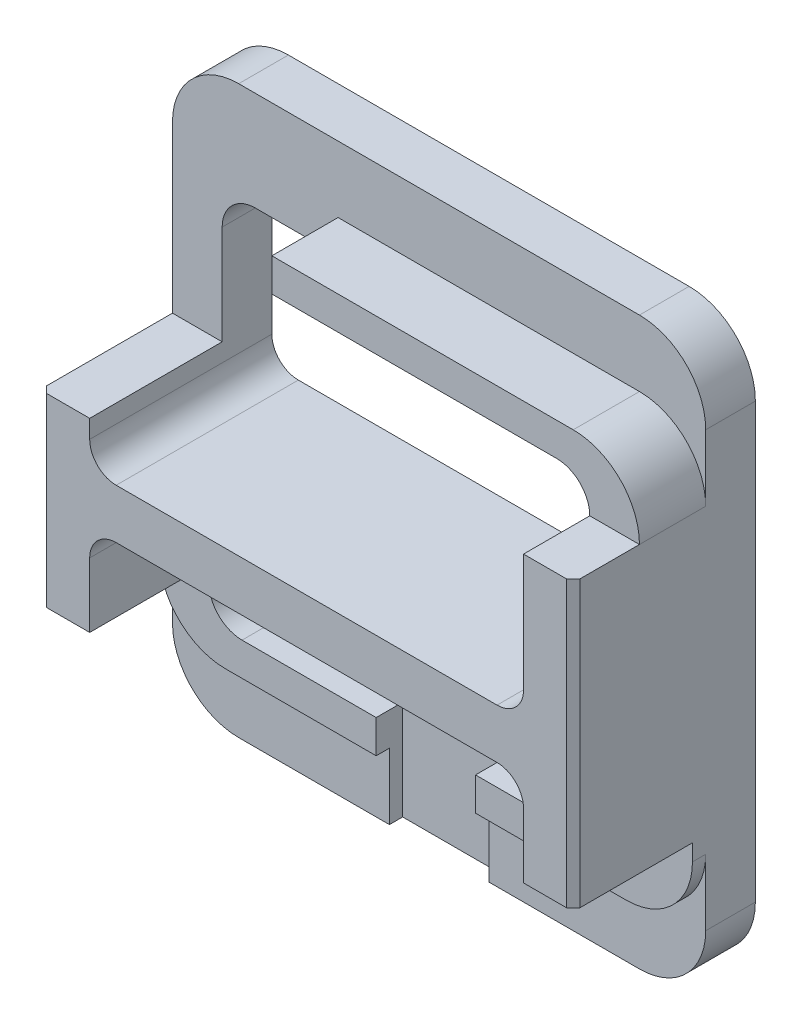
from build123d import *

# Parameters (mm, degrees)
BOSS_EXTRUDE1_DEPTH = 55
BOSS_EXTRUDE3_DEPTH = 15
SKETCH4_W           = 190.013565595
SKETCH4_H           = 25
CUT_EXTRUDE1_DEPTH  = 36
SKETCH5_W           = 30
SKETCH5_H           = 30
CUT_EXTRUDE2_DEPTH  = 8
SKETCH6_W           = 72.414600628
SKETCH6_H           = 59.825353167
CUT_EXTRUDE3_DEPTH  = 40
SKETCH7_W           = 143.244471566
SKETCH7_H           = 49.658158813
CUT_EXTRUDE4_DEPTH  = 20
SKETCH8_W           = 131
SKETCH8_H           = 15
BOSS_EXTRUDE4_DEPTH = 55
FILLET1_R           = 8
CHAMFER1_SIZE       = 2


with BuildPart() as part:
    # Sketch1 → Boss-Extrude1 (new body)
    with BuildSketch(Plane.XY):
        with BuildLine():
            Line((-60.5, 65.5), (60.5, 65.5))
            ThreePointArc((60.5, 65.5), (74.642135624, 59.642135624), (80.5, 45.5))
            Line((80.5, 45.5), (80.5, -45.5))
            ThreePointArc((80.5, -45.5), (74.642135624, -59.642135624), (60.5, -65.5))
            Line((60.5, -65.5), (-60.5, -65.5))
            ThreePointArc((-60.5, -65.5), (-74.642135624, -59.642135624), (-80.5, -45.5))
            Line((-80.5, -45.5), (-80.5, 45.5))
            ThreePointArc((-80.5, 45.5), (-74.642135624, 59.642135624), (-60.5, 65.5))
        make_face()
        with BuildLine():
            Line((-65.5, 45.5), (-65.5, -45.5))
            ThreePointArc((-65.5, -45.5), (-62.571067812, -52.571067812), (-55.5, -55.5))
            Line((-55.5, -55.5), (55.5, -55.5))
            ThreePointArc((55.5, -55.5), (62.571067812, -52.571067812), (65.5, -45.5))
            Line((65.5, -45.5), (65.5, 45.5))
            ThreePointArc((65.5, 45.5), (62.571067812, 52.571067812), (55.5, 55.5))
            Line((55.5, 55.5), (-55.5, 55.5))
            ThreePointArc((-55.5, 55.5), (-62.571067812, 52.571067812), (-65.5, 45.5))
        make_face(mode=Mode.SUBTRACT)
    extrude(amount=BOSS_EXTRUDE1_DEPTH)

    # Sketch3 → Boss-Extrude3 (add)
    with BuildSketch(Plane(origin=(0, 0, 0), x_dir=(-1, 0, 0), z_dir=(0, 0, -1))):
        with BuildLine():
            Line((-80.5, 45.5), (-80.5, 65.5))
            ThreePointArc((-80.5, 65.5), (-74.642135624, 79.642135624), (-60.5, 85.5))
            Line((-60.5, 85.5), (60.5, 85.5))
            ThreePointArc((60.5, 85.5), (74.642135624, 79.642135624), (80.5, 65.5))
            Line((80.5, 65.5), (80.5, 45.5))
            ThreePointArc((80.5, 45.5), (74.642135624, 59.642135624), (60.5, 65.5))
            Line((60.5, 65.5), (-60.5, 65.5))
            ThreePointArc((-60.5, 65.5), (-74.642135624, 59.642135624), (-80.5, 45.5))
        make_face()
        with BuildLine():
            Line((80.5, -45.5), (80.5, -65.5))
            ThreePointArc((80.5, -65.5), (74.642135624, -79.642135624), (60.5, -85.5))
            Line((60.5, -85.5), (-60.5, -85.5))
            ThreePointArc((-60.5, -85.5), (-74.642135624, -79.642135624), (-80.5, -65.5))
            Line((-80.5, -65.5), (-80.5, -45.5))
            ThreePointArc((-80.5, -45.5), (-74.642135624, -59.642135624), (-60.5, -65.5))
            Line((-60.5, -65.5), (60.5, -65.5))
            ThreePointArc((60.5, -65.5), (74.642135624, -59.642135624), (80.5, -45.5))
        make_face()
    extrude(amount=-BOSS_EXTRUDE3_DEPTH)

    # Sketch4 → Cut-Extrude1 (cut)
    with BuildSketch(Plane.XY.offset(55)):
        with Locations((-0.225937653, -53)):
            Rectangle(SKETCH4_W, SKETCH4_H)
    extrude(amount=-CUT_EXTRUDE1_DEPTH, mode=Mode.SUBTRACT)

    # Sketch5 → Cut-Extrude2 (cut)
    with BuildSketch(Plane.XY.offset(19)):
        with Locations((0, -70.5)):
            Rectangle(SKETCH5_W, SKETCH5_H)
    extrude(amount=-CUT_EXTRUDE2_DEPTH, mode=Mode.SUBTRACT)

    # Sketch6 → Cut-Extrude3 (cut)
    with BuildSketch(Plane.XY.offset(55)):
        with Locations((-66.707300314, 45.412676584)):
            Rectangle(SKETCH6_W, SKETCH6_H)
    extrude(amount=-CUT_EXTRUDE3_DEPTH, mode=Mode.SUBTRACT)

    # Sketch7 → Cut-Extrude4 (cut)
    with BuildSketch(Plane.XY.offset(55)):
        with Locations((34.229554325, 70.329079407)):
            Rectangle(SKETCH7_W, SKETCH7_H)
    extrude(amount=-CUT_EXTRUDE4_DEPTH, mode=Mode.SUBTRACT)

    # Sketch8 → Boss-Extrude4 (add)
    with BuildSketch(Plane(origin=(0, 0, 0), x_dir=(-1, 0, 0), z_dir=(0, 0, -1))):
        with Locations((0, -5.5)):
            Rectangle(SKETCH8_W, SKETCH8_H)
    extrude(amount=-BOSS_EXTRUDE4_DEPTH)

    # Fillet1
    fillet1_edges = [part.edges().sort_by_distance(p)[0] for p in [
        (-65.5, -13, 27.5),
        (-65.5, 2, 27.5),
        (65.5, 2, 27.5),
        (65.5, -13, 27.5),
    ]]
    fillet(fillet1_edges, radius=FILLET1_R)

    # Chamfer1
    chamfer1_edges = [part.edges().sort_by_distance(p)[0] for p in [
        (80.5, 2.5, 55),
        (-80.5, -12.5, 55),
    ]]
    chamfer(chamfer1_edges, length=CHAMFER1_SIZE)


solid = part.part
